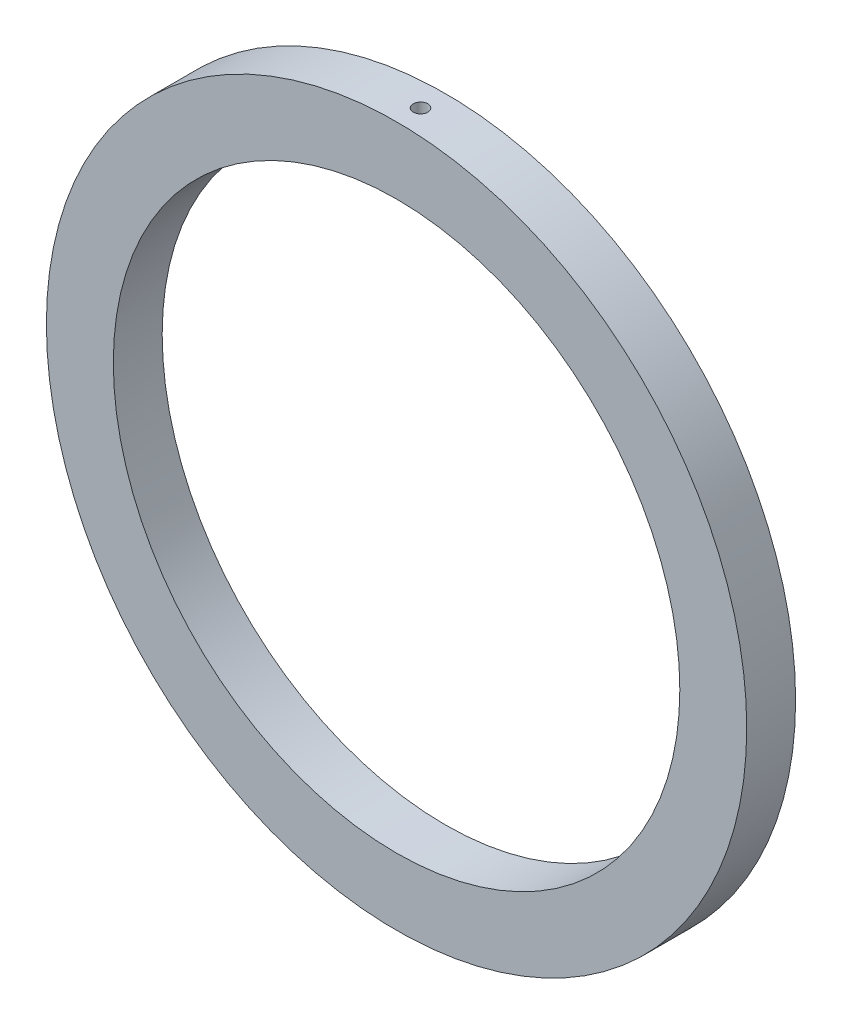
from build123d import *

# Parameters (mm, degrees)
SKETCH1_R                 = 28.575
SKETCH1_R_2               = 23.114
BOSS_EXTRUDE1_DEPTH       = 1.9939
BOSS_EXTRUDE1_DEPTH_BACK  = 1.9939
F_0_80_TAPPED_HOLE1_D     = 1.19126
F_0_80_TAPPED_HOLE1_DEPTH = 4.064
F_0_80_TAPPED_HOLE1_TIP   = 0.357890611


with BuildPart() as part:
    # Sketch1 → Boss-Extrude1 (new body, two sides)
    with BuildSketch(Plane.XY) as boss_extrude1_sk:
        Circle(SKETCH1_R)
        Circle(SKETCH1_R_2, mode=Mode.SUBTRACT)
    extrude(amount=BOSS_EXTRUDE1_DEPTH)
    extrude(boss_extrude1_sk.sketch, amount=-BOSS_EXTRUDE1_DEPTH_BACK)

    # #0-80 Tapped Hole1
    with Locations(Plane(origin=(0, 28.575, 0.041948097), x_dir=(1, 0, 0), z_dir=(0, 1, 0))):
        with Locations((0, 0)):
            Hole(F_0_80_TAPPED_HOLE1_D / 2, depth=F_0_80_TAPPED_HOLE1_DEPTH)
            with Locations((0, 0, -(F_0_80_TAPPED_HOLE1_DEPTH + F_0_80_TAPPED_HOLE1_TIP / 2))):  # 118° drill point
                Cone(0, F_0_80_TAPPED_HOLE1_D / 2, F_0_80_TAPPED_HOLE1_TIP, mode=Mode.SUBTRACT)


solid = part.part
